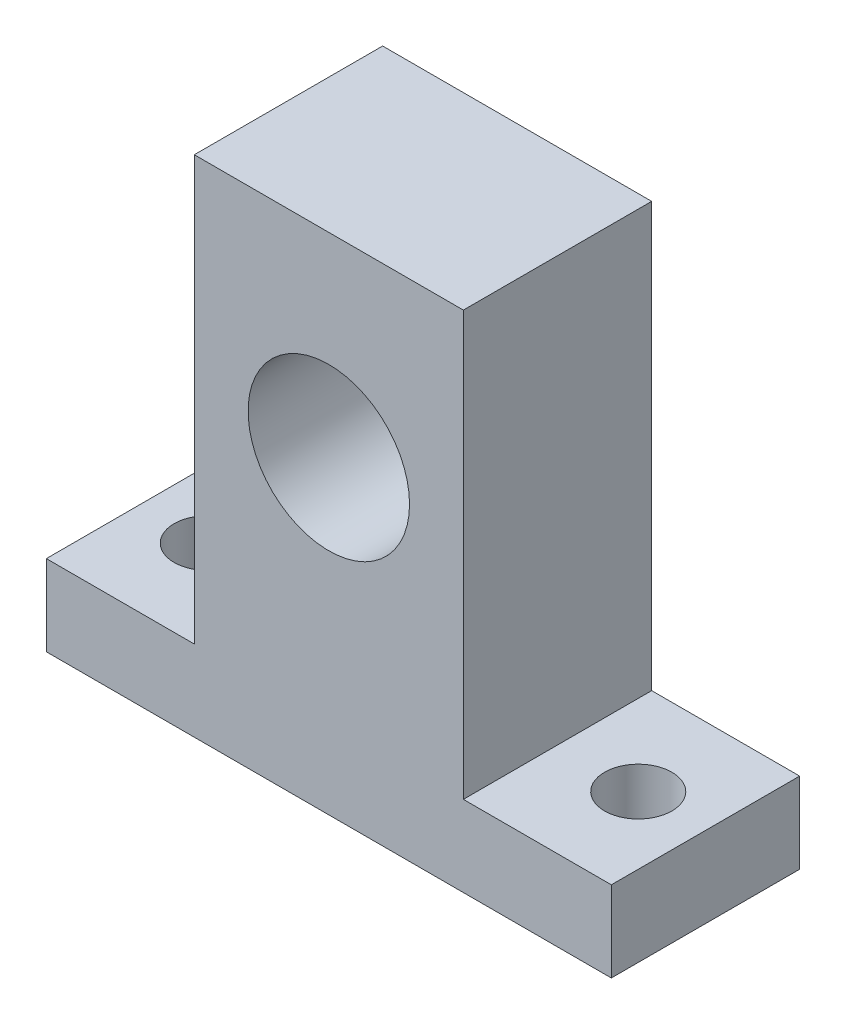
from build123d import *

# Parameters (mm, degrees)
BOSS_EXTRUDE1_DEPTH = 14
CUT_EXTRUDE1_REACH  = 39.5
SKETCH2_R           = 2.5
CUT_EXTRUDE2_REACH  = 16
SKETCH3_R           = 6


with BuildPart() as part:
    # Sketch1 → Boss-Extrude1 (new body)
    with BuildSketch(Plane.XY):
        Polygon((0, 0), (0, 6), (11, 6), (11, 37.5), (31, 37.5), (31, 6), (42, 6), (42, 0), align=None)
    extrude(amount=-BOSS_EXTRUDE1_DEPTH)

    # Sketch2 → Cut-Extrude1 (cut, up to next)
    with BuildSketch(Plane.XZ, mode=Mode.PRIVATE) as cut_extrude1_sk1:
        with Locations((5, -7)):
            Circle(SKETCH2_R)
    cut_extrude1_tool1 = extrude(cut_extrude1_sk1.sketch, amount=-CUT_EXTRUDE1_REACH, mode=Mode.PRIVATE) & part.part
    add(cut_extrude1_tool1.solids().sort_by_distance((5, 0, -7))[0], mode=Mode.SUBTRACT)
    # Sketch2 → Cut-Extrude1 (cut, up to next)
    with BuildSketch(Plane.XZ, mode=Mode.PRIVATE) as cut_extrude1_sk2:
        with Locations((37, -7)):
            Circle(SKETCH2_R)
    cut_extrude1_tool2 = extrude(cut_extrude1_sk2.sketch, amount=-CUT_EXTRUDE1_REACH, mode=Mode.PRIVATE) & part.part
    add(cut_extrude1_tool2.solids().sort_by_distance((37, 0, -7))[0], mode=Mode.SUBTRACT)

    # Sketch3 → Cut-Extrude2 (cut, up to next)
    with BuildSketch(Plane.XY, mode=Mode.PRIVATE) as cut_extrude2_sk1:
        with Locations((21, 23)):
            Circle(SKETCH3_R)
    cut_extrude2_tool1 = extrude(cut_extrude2_sk1.sketch, amount=-CUT_EXTRUDE2_REACH, mode=Mode.PRIVATE) & part.part
    add(cut_extrude2_tool1.solids().sort_by_distance((21, 23, 0))[0], mode=Mode.SUBTRACT)


solid = part.part
